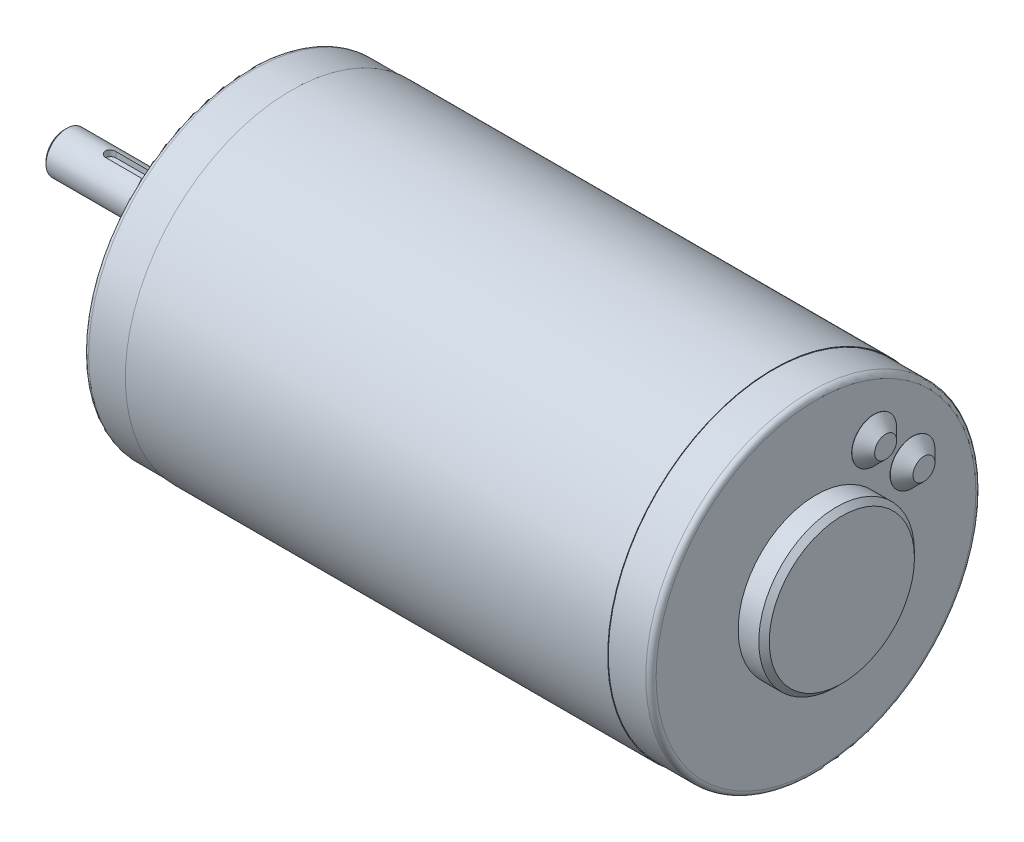
from build123d import *

# Parameters (mm, degrees)
SKETCH1_W                       = 93.1408
SKETCH1_H                       = 32.004
SKETCH2_R                       = 31.877
BOSS_EXTRUDE1_DEPTH             = 8.2296
SKETCH3_R                       = 15.0368
BOSS_EXTRUDE2_DEPTH             = 3.984
SKETCH4_R                       = 15.0368
BOSS_EXTRUDE3_DEPTH             = 1.016
BOSS_EXTRUDE3_TAPER             = 45
SKETCH5_R                       = 31.877
BOSS_EXTRUDE4_DEPTH             = 8.2296
SKETCH6_R                       = 9.525
BOSS_EXTRUDE5_DEPTH             = 4
SKETCH7_R                       = 4
BOSS_EXTRUDE6_DEPTH             = 31.6
CUT_EXTRUDE1_REACH              = 31.204
F_21_0_159_DIAMETER_HOLE1_D     = 4.0386
F_21_0_159_DIAMETER_HOLE1_DEPTH = 13.6144
F_21_0_159_DIAMETER_HOLE1_TIP   = 1.213317848
CHAMFER1_SIZE                   = 1.016
CHAMFER2_SIZE                   = 0.5
FILLET1_R                       = 1


with BuildPart() as part:
    # Sketch1 → Revolve1 (revolve)
    with BuildSketch(Plane.XY):
        with Locations((54.8, 16.002)):
            Rectangle(SKETCH1_W, SKETCH1_H)
    revolve(axis=Axis((8.2296, 0, 0), (1, 0, 0)))

    # Sketch2 → Boss-Extrude1 (add)
    with BuildSketch(Plane(origin=(101.3704, 0, 0), x_dir=(0, 0, -1), z_dir=(1, 0, 0))):
        Circle(SKETCH2_R)
    extrude(amount=BOSS_EXTRUDE1_DEPTH)

    # Sketch3 → Boss-Extrude2 (add)
    with BuildSketch(Plane(origin=(109.6, 0, 0), x_dir=(0, 0, -1), z_dir=(1, 0, 0))):
        Circle(SKETCH3_R)
    extrude(amount=BOSS_EXTRUDE2_DEPTH)

    # Sketch4 → Boss-Extrude3 (add)
    with BuildSketch(Plane(origin=(113.584, 0, 0), x_dir=(0, 0, -1), z_dir=(1, 0, 0))):
        Circle(SKETCH4_R)
    extrude(amount=BOSS_EXTRUDE3_DEPTH, taper=BOSS_EXTRUDE3_TAPER)

    # Sketch5 → Boss-Extrude4 (add)
    with BuildSketch(Plane.ZY.offset(-8.2296)):
        Circle(SKETCH5_R)
    extrude(amount=BOSS_EXTRUDE4_DEPTH)

    # Sketch6 → Boss-Extrude5 (add)
    with BuildSketch(Plane.ZY):
        Circle(SKETCH6_R)
    extrude(amount=BOSS_EXTRUDE5_DEPTH)

    # Sketch7 → Boss-Extrude6 (add)
    with BuildSketch(Plane.ZY.offset(4)):
        Circle(SKETCH7_R)
    extrude(amount=BOSS_EXTRUDE6_DEPTH)

    # Sketch8 → Cut-Extrude1 (cut, up to next)
    with BuildSketch(Plane.XZ.offset(-2.8), mode=Mode.PRIVATE) as cut_extrude1_sk1:
        with BuildLine():
            Line((-7.1, 1), (-26.6, 1))
            ThreePointArc((-26.6, 1), (-27.6, 0), (-26.6, -1))
            Line((-26.6, -1), (-7.1, -1))
            ThreePointArc((-7.1, -1), (-6.1, 0), (-7.1, 1))
        make_face()
    cut_extrude1_tool1 = extrude(cut_extrude1_sk1.sketch, amount=-CUT_EXTRUDE1_REACH, mode=Mode.PRIVATE) & part.part
    add(cut_extrude1_tool1.solids().sort_by_distance((-16.85, 2.8, 0))[0], mode=Mode.SUBTRACT)

    # Sketch9 → Revolve2 (revolve)
    with BuildSketch(Plane.XY.offset(-18.607090683)):
        Polygon((109.6, 15.525359639), (109.6, 11.207359639), (111.8479, 11.207359639), (111.8479, 13.325359639), (109.6479, 15.525359639), align=None)
    revolve(axis=Axis((109.6, 11.207359639, -18.607090683), (1, 0, 0)))

    # Sketch10 → Revolve3 (revolve)
    with BuildSketch(Plane.XY.offset(-11.207359639)):
        Polygon((109.6, 22.925090683), (109.6, 18.607090683), (111.8479, 18.607090683), (111.8479, 20.725090683), (109.6479, 22.925090683), align=None)
    revolve(axis=Axis((109.6, 18.607090683, -11.207359639), (1, 0, 0)))

    # #21 (0.159) Diameter Hole1
    with Locations(Plane.ZY):
        with Locations((0, 25.4), (0, -25.4)):
            Hole(F_21_0_159_DIAMETER_HOLE1_D / 2, depth=F_21_0_159_DIAMETER_HOLE1_DEPTH)
            with Locations((0, 0, -(F_21_0_159_DIAMETER_HOLE1_DEPTH + F_21_0_159_DIAMETER_HOLE1_TIP / 2))):  # 118° drill point
                Cone(0, F_21_0_159_DIAMETER_HOLE1_D / 2, F_21_0_159_DIAMETER_HOLE1_TIP, mode=Mode.SUBTRACT)

    # Chamfer1
    chamfer1_edges = [part.edges().sort_by_distance(p)[0] for p in [
        (-4, 0, -9.525),
    ]]
    chamfer(chamfer1_edges, length=CHAMFER1_SIZE)

    # Chamfer2
    chamfer2_edges = [part.edges().sort_by_distance(p)[0] for p in [
        (-35.6, 0, -4),
    ]]
    chamfer(chamfer2_edges, length=CHAMFER2_SIZE)

    # Fillet1
    fillet1_edges = [part.edges().sort_by_distance(p)[0] for p in [
        (0, 0, -31.877),
        (109.6, 0, 31.877),
    ]]
    fillet(fillet1_edges, radius=FILLET1_R)


solid = part.part
